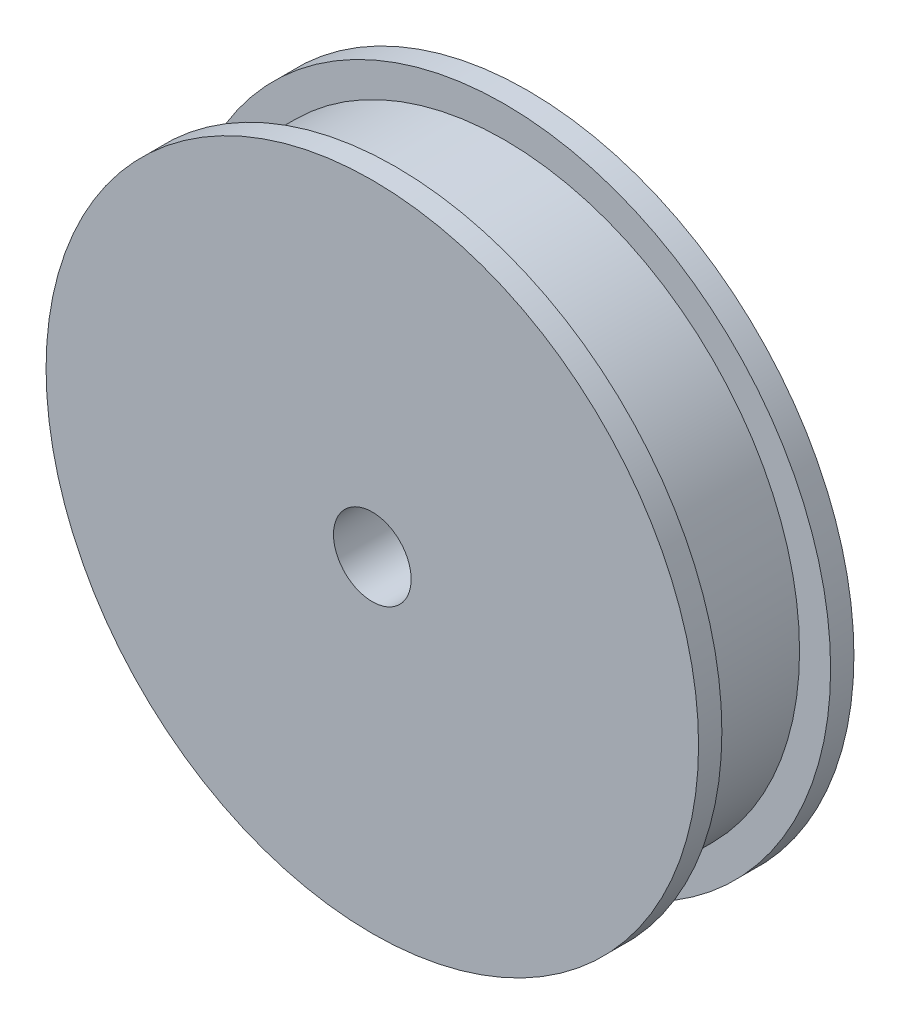
from build123d import *

# Parameters (mm, degrees)
SKETCH_3_R          = 10
EXTRUDE_1_DEPTH     = 7
SKETCH_4_R          = 2.5
CUT_EXTRUDE_1_DEPTH = 18


with BuildPart() as part:
    # Эскиз2 → Повернуть1 (revolve)
    with BuildSketch(Plane(origin=(0, 0, 0), x_dir=(0, 0, -1), z_dir=(1, 0, 0))):
        Polygon((0, 0), (0, 21), (1.5, 21), (1.5, 19), (8.5, 19), (8.5, 21), (10, 21), (10, 0), align=None)
    revolve(axis=Axis((0, 0, -10), (0, 0, 1)))

    # Эскиз3 → Бобышка-Вытянуть1 (add)
    with BuildSketch(Plane(origin=(0, 0, -10), x_dir=(-1, 0, 0), z_dir=(0, 0, -1))):
        Circle(SKETCH_3_R)
    extrude(amount=EXTRUDE_1_DEPTH)

    # Эскиз4 → Вырез-Вытянуть1 (cut, through all)
    with BuildSketch(Plane(origin=(0, 0, -17), x_dir=(-1, 0, 0), z_dir=(0, 0, -1))):
        Circle(SKETCH_4_R)
    extrude(amount=-CUT_EXTRUDE_1_DEPTH, mode=Mode.SUBTRACT)


solid = part.part
